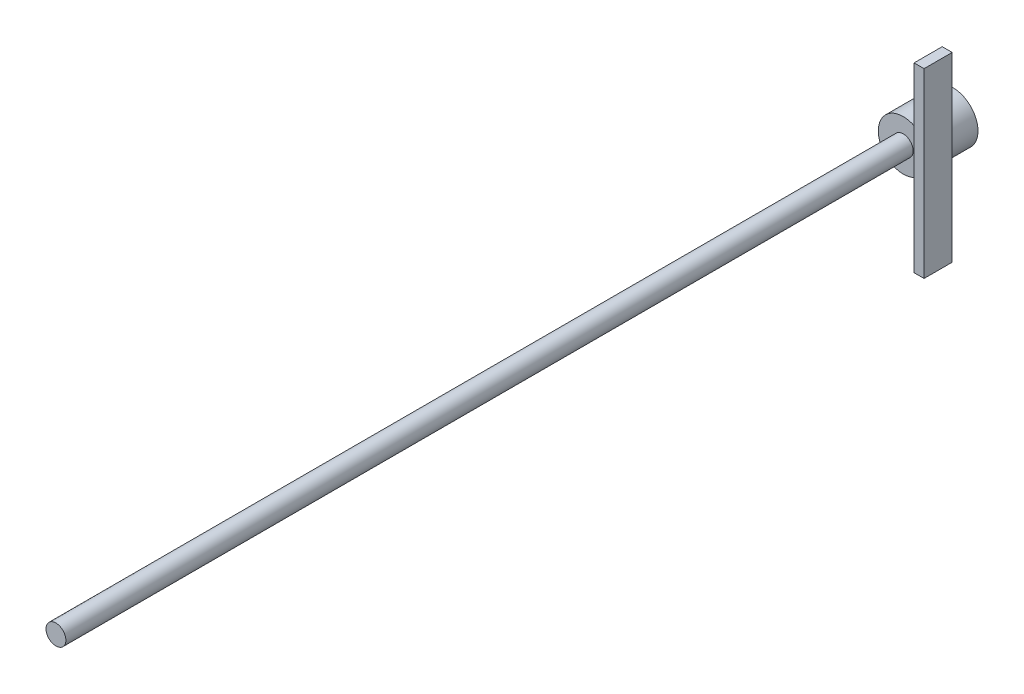
from build123d import *

# Parameters (mm, degrees)
ESQUISSE1_R        = 2.5
BOSS_EXTRU_1_DEPTH = 5
ESQUISSE2_R        = 0.997360315
BOSS_EXTRU_2_DEPTH = 90
ESQUISSE3_W        = 2.818851666
ESQUISSE3_H        = 18.231891376
BOSS_EXTRU_3_DEPTH = 1


with BuildPart() as part:
    # Esquisse1 → Boss.-Extru.1 (new body)
    with BuildSketch(Plane.XY):
        Circle(ESQUISSE1_R)
    extrude(amount=BOSS_EXTRU_1_DEPTH)

    # Esquisse2 → Boss.-Extru.2 (add)
    with BuildSketch(Plane.XY):
        Circle(ESQUISSE2_R)
    extrude(amount=BOSS_EXTRU_2_DEPTH)


with BuildPart() as body_2:
    # Esquisse3 → Boss.-Extru.3 (new body)
    with BuildSketch(Plane(origin=(2.5, 0, 0), x_dir=(0, 0, -1), z_dir=(1, 0, 0))):
        with Locations((-5, 0)):
            Rectangle(ESQUISSE3_W, ESQUISSE3_H)
    extrude(amount=BOSS_EXTRU_3_DEPTH)


solid = Compound([part.part, body_2.part])
